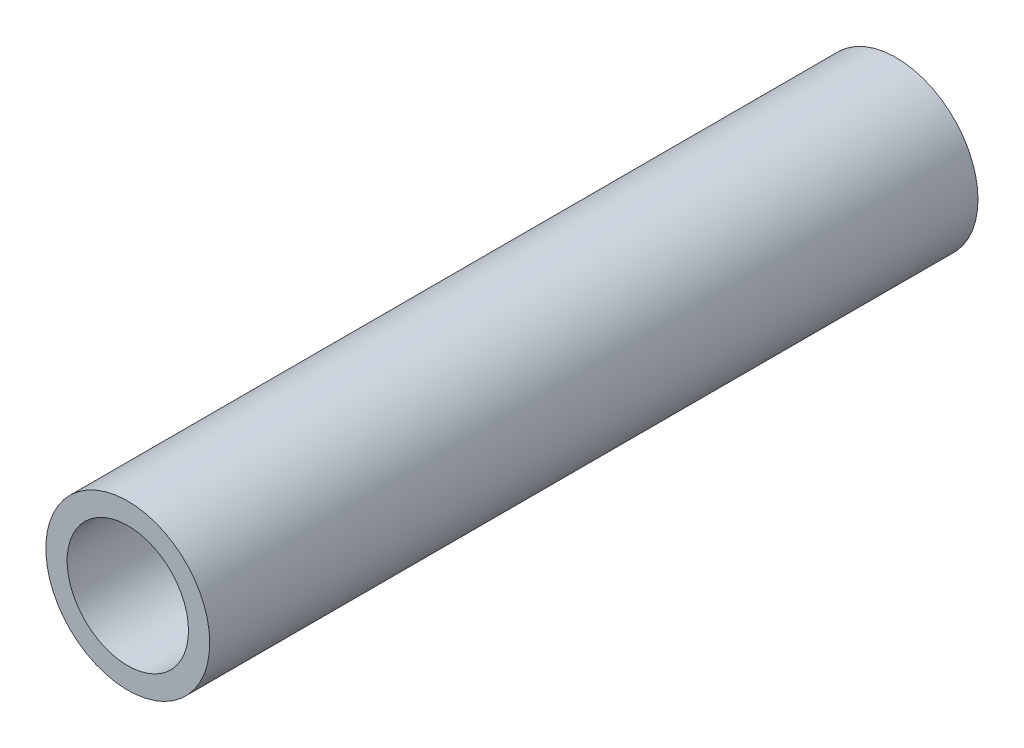
from build123d import *

# Parameters (mm, degrees)
SKETCH1_R           = 10.668
SKETCH1_R_2         = 7.8994
EXTRUDE_THIN1_DEPTH = 50


with BuildPart() as part:
    # Sketch1 → Extrude-Thin1 (new body, symmetric)
    with BuildSketch(Plane.XY):
        Circle(SKETCH1_R)
        Circle(SKETCH1_R_2, mode=Mode.SUBTRACT)
    extrude(amount=EXTRUDE_THIN1_DEPTH, both=True)


solid = part.part
